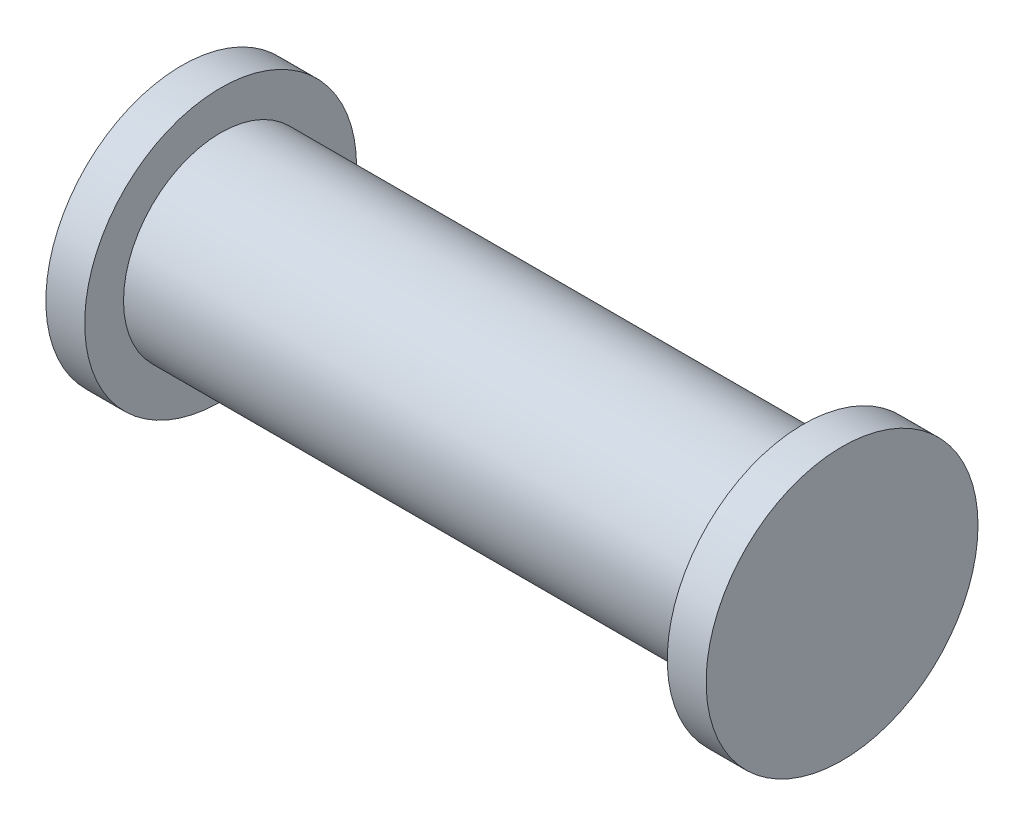
from build123d import *

# Parameters (mm, degrees)
SKETCH1_R           = 12.5
BOSS_EXTRUDE1_DEPTH = 37.5
SKETCH4_R           = 17.5
BOSS_EXTRUDE3_DEPTH = 5


with BuildPart() as part:
    # Sketch1 → Boss-Extrude1 (new body, symmetric)
    with BuildSketch(Plane(origin=(0, 0, 0), x_dir=(0, 0, -1), z_dir=(1, 0, 0))):
        Circle(SKETCH1_R)
    extrude(amount=BOSS_EXTRUDE1_DEPTH, both=True)

    # Sketch4 → Boss-Extrude3 (add)
    with BuildSketch(Plane(origin=(37.5, 0, 0), x_dir=(0, 0, -1), z_dir=(1, 0, 0))):
        Circle(SKETCH4_R)
    boss_extrude3 = extrude(amount=BOSS_EXTRUDE3_DEPTH)

    # Mirror1: Boss-Extrude3 across plane
    add(boss_extrude3.mirror(Plane(origin=(0, 0, 0), x_dir=(0, 0, 1), z_dir=(1, 0, 0))))


solid = part.part
